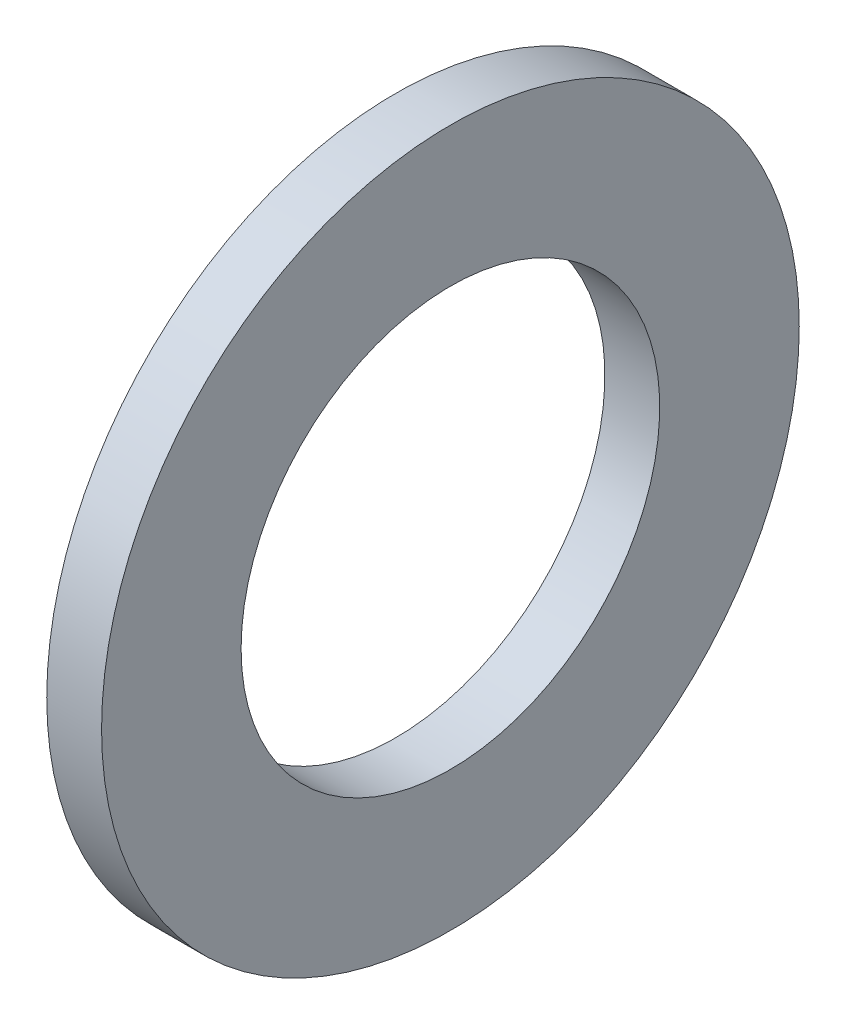
from build123d import *

# Parameters (mm, degrees)
SKETCH1_W = 2.75
SKETCH1_H = 7


with BuildPart() as part:
    # Sketch1 → Revolve1 (revolve)
    with BuildSketch(Plane.XY):
        with Locations((-2.375, 14)):
            Rectangle(SKETCH1_W, SKETCH1_H)
    revolve(axis=Axis((50, 0, 0), (-1, 0, 0)))


solid = part.part
